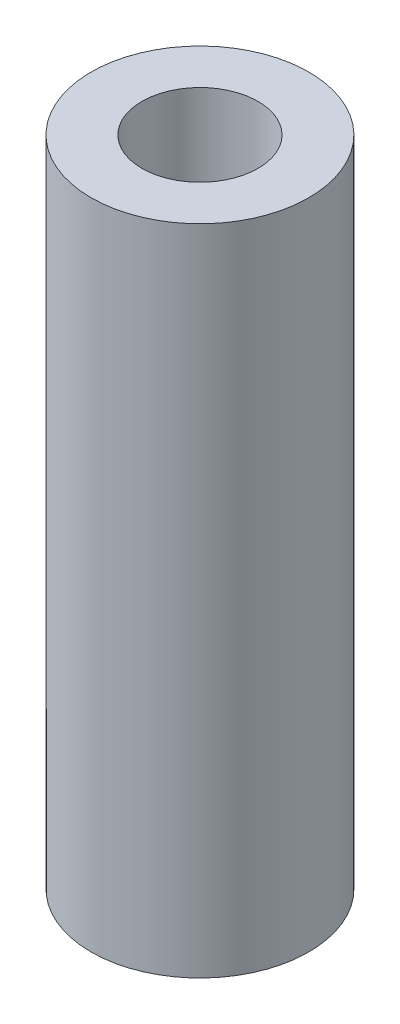
from build123d import *

# Parameters (mm, degrees)
SKETCH1_R           = 3
SKETCH1_R_2         = 1.6
BOSS_EXTRUDE1_DEPTH = 18


with BuildPart() as part:
    # Sketch1 → Boss-Extrude1 (new body)
    with BuildSketch(Plane(origin=(0, 0, 0), x_dir=(1, 0, 0), z_dir=(0, 1, 0))):
        Circle(SKETCH1_R)
        Circle(SKETCH1_R_2, mode=Mode.SUBTRACT)
    extrude(amount=BOSS_EXTRUDE1_DEPTH)


solid = part.part
